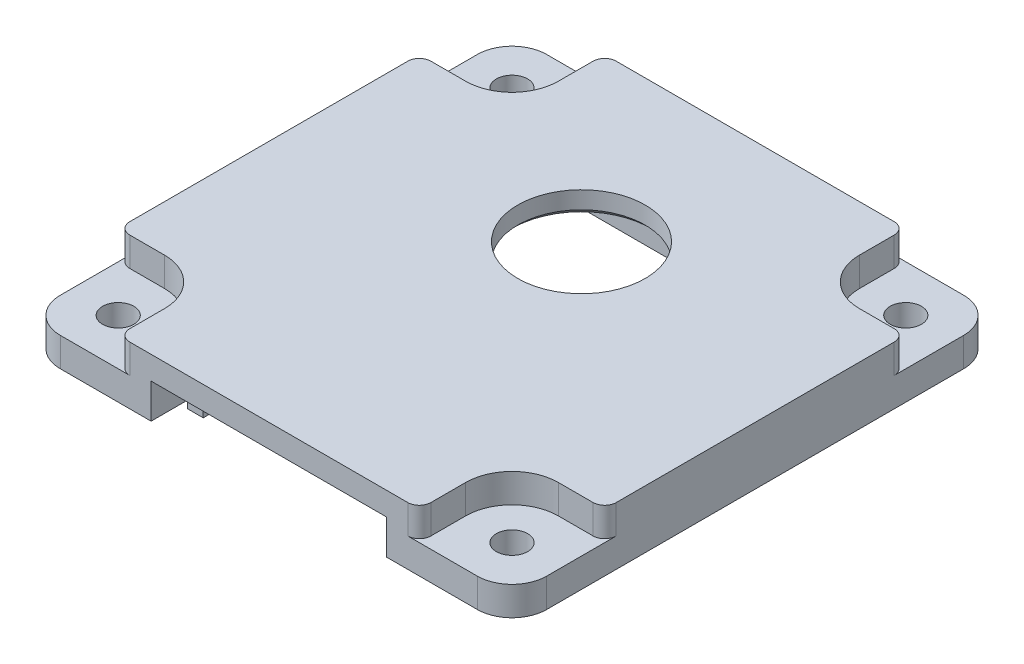
from build123d import *

# Parameters (mm, degrees)
SKETCH2_W           = 42
SKETCH2_H           = 42
SKETCH2_R           = 5.5
BOSS_EXTRUDE1_DEPTH = 2
SKETCH4_W           = 42
SKETCH4_H           = 42
BOSS_EXTRUDE2_DEPTH = 3
BOSS_EXTRUDE3_DEPTH = 3
BOSS_EXTRUDE5_DEPTH = 5
CUT_EXTRUDE1_DEPTH  = 2.5
SKETCH9_R           = 1.35
CUT_EXTRUDE2_DEPTH  = 8
FILLET1_R           = 3
FILLET2_R           = 1
CHAMFER1_SIZE       = 0.5
SKETCH10_W          = 20.32
SKETCH10_H          = 5
CUT_EXTRUDE3_DEPTH  = 5.5


with BuildPart() as part:
    # Sketch2 → Boss-Extrude1 (new body)
    with BuildSketch(Plane(origin=(0, 0, 0), x_dir=(1, 0, 0), z_dir=(0, 1, 0))):
        Rectangle(SKETCH2_W, SKETCH2_H)
        with Locations((0, 6)):
            Circle(SKETCH2_R, mode=Mode.SUBTRACT)
    extrude(amount=-BOSS_EXTRUDE1_DEPTH)

    # Sketch4 → Boss-Extrude2 (add)
    with BuildSketch(Plane.XZ.offset(2)):
        Rectangle(SKETCH4_W, SKETCH4_H)
        with BuildLine():
            Line((-17, 11.522774425), (-17, -11.522774425))
            ThreePointArc((-17, -11.522774425), (-16.869274473, -11.859874356), (-16.545454545, -12.020704023))
            ThreePointArc((-16.545454545, -12.020704023), (-13.464466094, -13.464466094), (-12.020704023, -16.545454545))
            ThreePointArc((-12.020704023, -16.545454545), (-11.859874356, -16.869274473), (-11.522774425, -17))
            Line((-11.522774425, -17), (11.522774425, -17))
            ThreePointArc((11.522774425, -17), (11.859874356, -16.869274473), (12.020704023, -16.545454545))
            ThreePointArc((12.020704023, -16.545454545), (13.464466094, -13.464466094), (16.545454545, -12.020704023))
            ThreePointArc((16.545454545, -12.020704023), (16.869274473, -11.859874356), (17, -11.522774425))
            Line((17, -11.522774425), (17, 11.522774425))
            ThreePointArc((17, 11.522774425), (16.869274473, 11.859874356), (16.545454545, 12.020704023))
            ThreePointArc((16.545454545, 12.020704023), (13.464466094, 13.464466094), (12.020704023, 16.545454545))
            ThreePointArc((12.020704023, 16.545454545), (11.859874356, 16.869274473), (11.522774425, 17))
            Line((11.522774425, 17), (-11.522774425, 17))
            ThreePointArc((-11.522774425, 17), (-11.859874356, 16.869274473), (-12.020704023, 16.545454545))
            ThreePointArc((-12.020704023, 16.545454545), (-13.464466094, 13.464466094), (-16.545454545, 12.020704023))
            ThreePointArc((-16.545454545, 12.020704023), (-16.869274473, 11.859874356), (-17, 11.522774425))
        make_face(mode=Mode.SUBTRACT)
    extrude(amount=BOSS_EXTRUDE2_DEPTH)

    # Sketch6 → Boss-Extrude3 (add)
    with BuildSketch(Plane.XZ.offset(2)):
        with BuildLine():
            Line((-17, 11.522774425), (-17, -11.522774425))
            ThreePointArc((-17, -11.522774425), (-16.869274473, -11.859874356), (-16.545454545, -12.020704023))
            ThreePointArc((-16.545454545, -12.020704023), (-13.464466094, -13.464466094), (-12.020704023, -16.545454545))
            ThreePointArc((-12.020704023, -16.545454545), (-11.859874356, -16.869274473), (-11.522774425, -17))
            Line((-11.522774425, -17), (11.522774425, -17))
            ThreePointArc((11.522774425, -17), (11.859874356, -16.869274473), (12.020704023, -16.545454545))
            ThreePointArc((12.020704023, -16.545454545), (13.464466094, -13.464466094), (16.545454545, -12.020704023))
            ThreePointArc((16.545454545, -12.020704023), (16.869274473, -11.859874356), (17, -11.522774425))
            Line((17, -11.522774425), (17, 11.522774425))
            ThreePointArc((17, 11.522774425), (16.869274473, 11.859874356), (16.545454545, 12.020704023))
            ThreePointArc((16.545454545, 12.020704023), (13.464466094, 13.464466094), (12.020704023, 16.545454545))
            ThreePointArc((12.020704023, 16.545454545), (11.859874356, 16.869274473), (11.522774425, 17))
            Line((11.522774425, 17), (-11.522774425, 17))
            ThreePointArc((-11.522774425, 17), (-11.859874356, 16.869274473), (-12.020704023, 16.545454545))
            ThreePointArc((-12.020704023, 16.545454545), (-13.464466094, 13.464466094), (-16.545454545, 12.020704023))
            ThreePointArc((-16.545454545, 12.020704023), (-16.869274473, 11.859874356), (-17, 11.522774425))
        make_face()
        with BuildLine():
            Line((-16.5, 11.522774425), (-16.5, -11.522774425))
            ThreePointArc((-16.5, -11.522774425), (-13.110912703, -13.110912703), (-11.522774425, -16.5))
            Line((-11.522774425, -16.5), (11.522774425, -16.5))
            ThreePointArc((11.522774425, -16.5), (13.110912703, -13.110912703), (16.5, -11.522774425))
            Line((16.5, -11.522774425), (16.5, 11.522774425))
            ThreePointArc((16.5, 11.522774425), (13.110912703, 13.110912703), (11.522774425, 16.5))
            Line((11.522774425, 16.5), (-11.522774425, 16.5))
            ThreePointArc((-11.522774425, 16.5), (-13.110912703, 13.110912703), (-16.5, 11.522774425))
        make_face(mode=Mode.SUBTRACT)
    extrude(amount=BOSS_EXTRUDE3_DEPTH)

    # Sketch7 → Boss-Extrude5 (add)
    with BuildSketch(Plane.XZ.offset(2)):
        with BuildLine():
            Line((11.522774425, 16.5), (-11.522774425, 16.5))
            ThreePointArc((-11.522774425, 16.5), (-13.110912703, 13.110912703), (-16.5, 11.522774425))
            Line((-16.5, 11.522774425), (-16.5, -11.522774425))
            ThreePointArc((-16.5, -11.522774425), (-13.110912703, -13.110912703), (-11.522774425, -16.5))
            Line((-11.522774425, -16.5), (11.522774425, -16.5))
            ThreePointArc((11.522774425, -16.5), (13.110912703, -13.110912703), (16.5, -11.522774425))
            Line((16.5, -11.522774425), (16.5, 11.522774425))
            ThreePointArc((16.5, 11.522774425), (13.110912703, 13.110912703), (11.522774425, 16.5))
        make_face()
        with BuildLine():
            Line((10.67544468, 15.5), (-10.67544468, 15.5))
            ThreePointArc((-10.67544468, 15.5), (-12.403805922, 12.403805922), (-15.5, 10.67544468))
            Line((-15.5, 10.67544468), (-15.5, -10.67544468))
            ThreePointArc((-15.5, -10.67544468), (-12.403805922, -12.403805922), (-10.67544468, -15.5))
            Line((-10.67544468, -15.5), (10.67544468, -15.5))
            ThreePointArc((10.67544468, -15.5), (12.403805922, -12.403805922), (15.5, -10.67544468))
            Line((15.5, -10.67544468), (15.5, 10.67544468))
            ThreePointArc((15.5, 10.67544468), (12.403805922, 12.403805922), (10.67544468, 15.5))
        make_face(mode=Mode.SUBTRACT)
    extrude(amount=BOSS_EXTRUDE5_DEPTH)

    # Sketch8 → Cut-Extrude1 (cut)
    with BuildSketch(Plane(origin=(0, 0, 0), x_dir=(1, 0, 0), z_dir=(0, 1, 0))):
        with BuildLine():
            Line((-17, 13), (-21, 13))
            Line((-21, 13), (-21, 21))
            Line((-21, 21), (-13, 21))
            Line((-13, 21), (-13, 17))
            ThreePointArc((-13, 17), (-14.171572875, 14.171572875), (-17, 13))
        make_face()
        with BuildLine():
            Line((13, 17), (13, 21))
            Line((13, 21), (21, 21))
            Line((21, 21), (21, 13))
            Line((21, 13), (17, 13))
            ThreePointArc((17, 13), (14.171572875, 14.171572875), (13, 17))
        make_face()
        with BuildLine():
            Line((-21, -17), (-21, -21))
            Line((-21, -21), (-17, -21))
            Line((-17, -21), (-13, -21))
            Line((-13, -21), (-13, -17))
            ThreePointArc((-13, -17), (-14.171572875, -14.171572875), (-17, -13))
            Line((-17, -13), (-21, -13))
            Line((-21, -13), (-21, -17))
        make_face()
        with BuildLine():
            Line((17, -13), (21, -13))
            Line((21, -13), (21, -21))
            Line((21, -21), (17, -21))
            Line((17, -21), (13, -21))
            Line((13, -21), (13, -17))
            ThreePointArc((13, -17), (14.171572875, -14.171572875), (17, -13))
        make_face()
    extrude(amount=-CUT_EXTRUDE1_DEPTH, mode=Mode.SUBTRACT)

    # Sketch9 → Cut-Extrude2 (cut, through all)
    with BuildSketch(Plane(origin=(0, 0, 0), x_dir=(1, 0, 0), z_dir=(0, 1, 0))):
        with Locations((-17, 17)):
            Circle(SKETCH9_R)
        with Locations((17, 17)):
            Circle(SKETCH9_R)
        with Locations((-17, -17)):
            Circle(SKETCH9_R)
        with Locations((17, -17)):
            Circle(SKETCH9_R)
    extrude(amount=-CUT_EXTRUDE2_DEPTH, mode=Mode.SUBTRACT)

    # Fillet1
    fillet1_edges = [part.edges().sort_by_distance(p)[0] for p in [
        (21, -3.75, 21),
        (-21, -3.75, 21),
        (-21, -3.75, -21),
        (21, -3.75, -21),
    ]]
    fillet(fillet1_edges, radius=FILLET1_R)

    # Fillet2
    fillet2_edges = [part.edges().sort_by_distance(p)[0] for p in [
        (13, -1.25, -21),
        (21, -1.25, -13),
        (-21, -1.25, 13),
        (-13, -1.25, 21),
        (21, -1.25, 13),
        (13, -1.25, 21),
        (-21, -1.25, -13),
        (-13, -1.25, -21),
    ]]
    fillet(fillet2_edges, radius=FILLET2_R)

    # Chamfer1
    chamfer1_edges = [part.edges().sort_by_distance(p)[0] for p in [
        (-5.5, -2, -6),
    ]]
    chamfer(chamfer1_edges, length=CHAMFER1_SIZE)

    # Sketch10 → Cut-Extrude3 (cut)
    with BuildSketch(Plane.XY.offset(21)):
        with Locations((0, -4.5)):
            Rectangle(SKETCH10_W, SKETCH10_H)
    extrude(amount=-CUT_EXTRUDE3_DEPTH, mode=Mode.SUBTRACT)


solid = part.part
